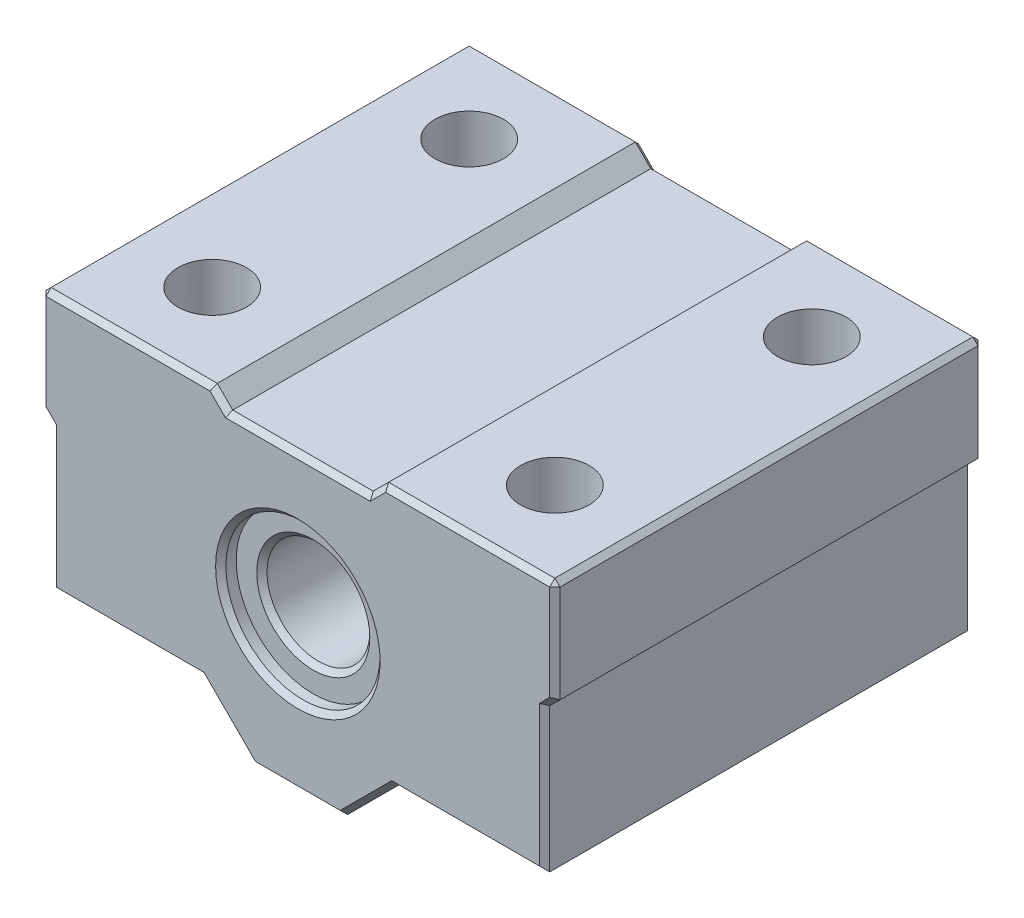
from build123d import *

# Parameters (mm, degrees)
SKETCH1_R           = 3
BOSS_EXTRUDE1_DEPTH = 12.5
SKETCH6_R           = 4.5
CUT_EXTRUDE2_DEPTH  = 0.9
CHAMFER2_SIZE       = 0.3
CHAMFER1_SIZE       = 0.3
CUT_EXTRUDE3_START  = -8
SKETCH7_R           = 2
CUT_EXTRUDE3_DEPTH  = 8
SKETCH13_R          = 1.7
CUT_EXTRUDE4_DEPTH  = 19


with BuildPart() as part:
    # Sketch1 → Boss-Extrude1 (new body, symmetric)
    with BuildSketch(Plane.XY):
        Polygon((-2.6, 0), (2.6, 0), (5.6, 3), (14.4, 3), (14.4, 11.4), (15, 12), (15, 18), (5, 18), (4.1, 17.1), (-4.1, 17.1), (-5, 18), (-15, 18), (-15, 12), (-14.4, 11.4), (-14.4, 3), (-5.6, 3), align=None)
        with Locations((0, 9)):
            Circle(SKETCH1_R, mode=Mode.SUBTRACT)
    extrude(amount=BOSS_EXTRUDE1_DEPTH, both=True)

    # Sketch6 → Cut-Extrude2 (cut)
    with BuildSketch(Plane.XY.offset(12.5)):
        with Locations((0, 9)):
            Circle(SKETCH6_R)
    cut_extrude2 = extrude(amount=-CUT_EXTRUDE2_DEPTH, mode=Mode.SUBTRACT)

    # Mirror3: Cut-Extrude2 across plane
    add(cut_extrude2.mirror(Plane.XY), mode=Mode.SUBTRACT)

    # Chamfer2
    chamfer2_edges = [part.edges().sort_by_distance(p)[0] for p in [
        (-3, 9, 11.6),
        (-4.5, 9, 12.5),
        (-4.5, 9, -12.5),
        (-3, 9, -11.6),
    ]]
    chamfer(chamfer2_edges, length=CHAMFER2_SIZE)

    # Chamfer1
    chamfer1_edges = [part.edges().sort_by_distance(p)[0] for p in [
        (4.1, 1.5, 12.5),
        (10, 3, 12.5),
        (-10, 3, -12.5),
        (-14.4, 7.2, -12.5),
        (-14.7, 11.7, -12.5),
        (-15, 15, -12.5),
        (-10, 18, -12.5),
        (14.4, 7.2, 12.5),
        (-4.55, 17.55, -12.5),
        (0, 17.1, -12.5),
        (4.55, 17.55, -12.5),
        (10, 18, -12.5),
        (15, 15, -12.5),
        (14.7, 11.7, -12.5),
        (14.4, 7.2, -12.5),
        (10, 3, -12.5),
        (14.7, 11.7, 12.5),
        (4.1, 1.5, -12.5),
        (0, 0, -12.5),
        (-4.1, 1.5, -12.5),
        (15, 15, 12.5),
        (10, 18, 12.5),
        (-15, 18, 0),
        (15, 18, 0),
        (4.55, 17.55, 12.5),
        (0, 17.1, 12.5),
        (-4.55, 17.55, 12.5),
        (-10, 18, 12.5),
        (-4.1, 1.5, 12.5),
        (-15, 15, 12.5),
        (-14.7, 11.7, 12.5),
        (-14.4, 7.2, 12.5),
        (-10, 3, 12.5),
        (0, 0, 12.5),
    ]]
    chamfer(chamfer1_edges, length=CHAMFER1_SIZE)

    # Sketch7 → Cut-Extrude3 (cut)
    with BuildSketch(Plane(origin=(0, 18, 0), x_dir=(1, 0, 0), z_dir=(0, 1, 0)).offset(CUT_EXTRUDE3_START)):
        with Locations(Location((10, -7.5, 0), (0, 0, 180))):  # turned: the seam where the file's is
            Circle(SKETCH7_R)
        with Locations(Location((10, 7.5, 0), (0, 0, 270))):  # turned: the seam where the file's is
            Circle(SKETCH7_R)
        with Locations(Location((-10, -7.5, 0), (0, 0, 270))):  # turned: the seam where the file's is
            Circle(SKETCH7_R)
        with Locations(Location((-10, 7.5, 0), (0, 0, 180))):  # turned: the seam where the file's is
            Circle(SKETCH7_R)
    extrude(amount=CUT_EXTRUDE3_DEPTH, mode=Mode.SUBTRACT)

    # Sketch13 → Cut-Extrude4 (cut, through all)
    with BuildSketch(Plane(origin=(0, 18, 0), x_dir=(1, 0, 0), z_dir=(0, 1, 0))):
        with Locations(Location((10, -7.5, 0), (0, 0, 270))):  # turned: the seam where the file's is
            Circle(SKETCH13_R)
        with Locations(Location((10, 7.5, 0), (0, 0, 270))):  # turned: the seam where the file's is
            Circle(SKETCH13_R)
        with Locations(Location((-10, -7.5, 0), (0, 0, 270))):  # turned: the seam where the file's is
            Circle(SKETCH13_R)
        with Locations(Location((-10, 7.5, 0), (0, 0, 270))):  # turned: the seam where the file's is
            Circle(SKETCH13_R)
    extrude(amount=-CUT_EXTRUDE4_DEPTH, mode=Mode.SUBTRACT)


solid = part.part
